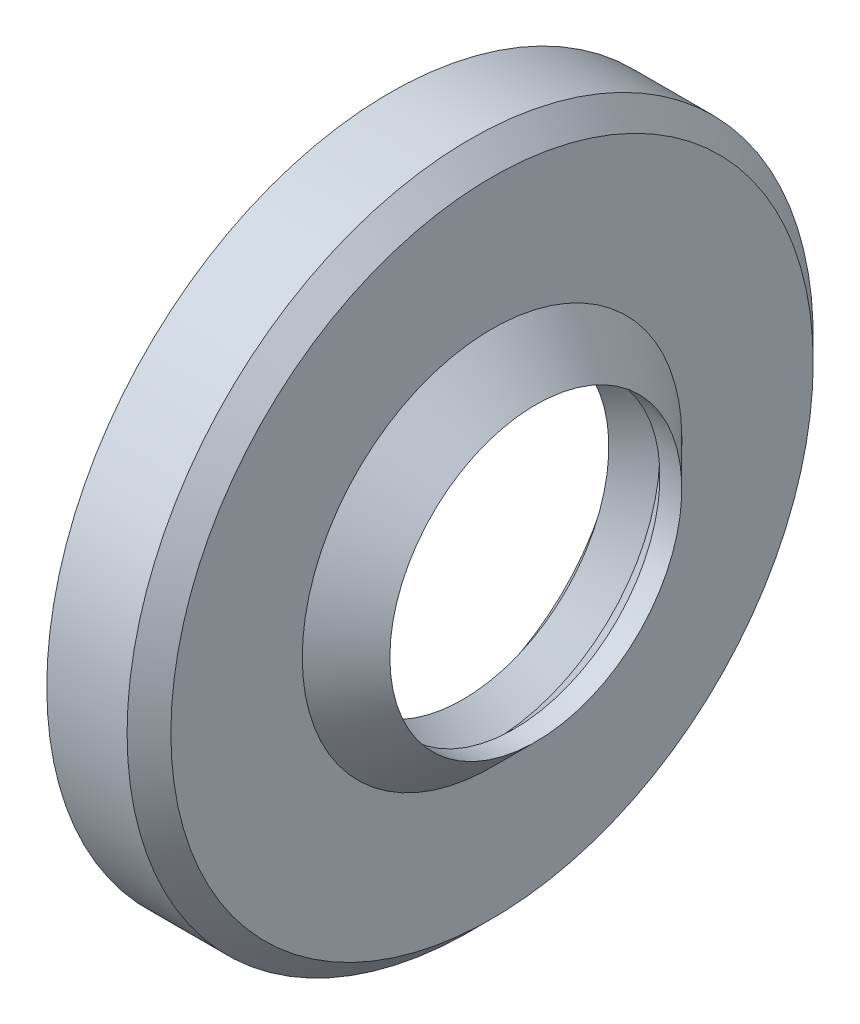
from build123d import *


with BuildPart() as part:
    # Эскиз1 → Повернуть1 (revolve)
    with BuildSketch(Plane.XY):
        Polygon((0, 22), (0, 23.5), (5.5, 23.5), (7, 22), (7, 13), (10, 10), (8.5, 10), (7, 11.5), (5, 10), (2.75, 13), (2.75, 14.5), (5.5, 14.5), (5.5, 22), align=None)
    revolve(axis=Axis((-1000, 0, 0), (1, 0, 0)))


solid = part.part
